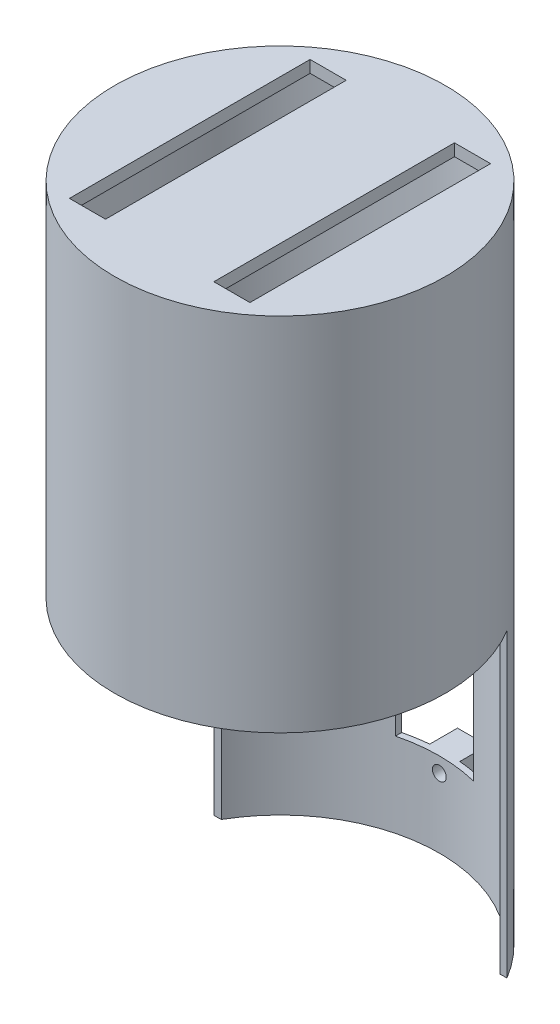
from build123d import *

# Parameters (mm, degrees)
EXTRUDE_1_DEPTH           = 60
EXTRUDE_1_DEPTH_BACK      = 50
SKETCH_1_R                = 27.5
SKETCH_10_W               = 6
SKETCH_10_H               = 40
CUT_EXTRUDE_8_DEPTH       = 8.1
CUT_EXTRUDE_9_DEPTH       = 10
CUT_EXTRUDE_9_DEPTH_BACK  = 10
SKETCH_10_2_W             = 6
SKETCH_10_2_H             = 40
CUT_EXTRUDE_10_DEPTH      = 54
CUT_EXTRUDE_11_DEPTH      = 58
CUT_EXTRUDE_11_DEPTH_BACK = 54
SKETCH_12_R               = 26.5
SKETCH_13_W               = 13
SKETCH_13_H               = 23.5
CUT_EXTRUDE_12_DEPTH      = 54
EXTRUDE_2_DEPTH           = 1
EXTRUDE_2_DEPTH_BACK      = 4
SKETCH_14_W               = 5
SKETCH_14_H               = 5
CUT_EXTRUDE_13_DEPTH      = 4
CUT_EXTRUDE_13_DEPTH_BACK = 5
SKETCH_15_R               = 1.15


with BuildPart() as part:
    # 草圖1 → 填料-伸長1 (new, two sides: drawn at the far end of the back side and taken through both)
    with BuildSketch(Plane(origin=(0, 0, 0), x_dir=(1, 0, 0), z_dir=(0, 1, 0)).offset(-EXTRUDE_1_DEPTH_BACK)):
        Circle(SKETCH_1_R)
    extrude(amount=EXTRUDE_1_DEPTH + EXTRUDE_1_DEPTH_BACK)

    # 草圖10 → 除料-伸長8 (cut)
    with BuildSketch(Plane(origin=(0, 60, 0), x_dir=(1, 0, 0), z_dir=(0, 1, 0))):
        with Locations((-12, 0)):
            Rectangle(SKETCH_10_W, SKETCH_10_H)
        with Locations((12, 0)):
            Rectangle(SKETCH_10_W, SKETCH_10_H)
    extrude(amount=-CUT_EXTRUDE_8_DEPTH, mode=Mode.SUBTRACT)

    # 草圖10<2> → 除料-伸長9 (cut, two sides: drawn at the far end of the back side and taken through both)
    with BuildSketch(Plane(origin=(0, 60, 0), x_dir=(1, 0, 0), z_dir=(0, 1, 0)).offset(-CUT_EXTRUDE_9_DEPTH_BACK)):
        with Locations((-12, 0)):
            Rectangle(SKETCH_10_2_W, SKETCH_10_2_H)
        with Locations((12, 0)):
            Rectangle(SKETCH_10_2_W, SKETCH_10_2_H)
    extrude(amount=CUT_EXTRUDE_9_DEPTH + CUT_EXTRUDE_9_DEPTH_BACK, mode=Mode.SUBTRACT)

    # 草圖11 → 除料-伸長10 (cut)
    with BuildSketch(Plane(origin=(0, 0, 0), x_dir=(1, 0, 0), z_dir=(0, 1, 0))):
        with BuildLine():
            Line((23.587956714, 14.137124816), (-24.13203639, 13.186918505))
            ThreePointArc((-24.13203639, 13.186918505), (0.547474823, -27.494549848), (23.587956714, 14.137124816))
        make_face()
    extrude(amount=-CUT_EXTRUDE_10_DEPTH, mode=Mode.SUBTRACT)

    # 草圖12 → 除料-伸長11 (cut, two sides: drawn at the far end of the back side and taken through both)
    with BuildSketch(Plane(origin=(0, 0, 0), x_dir=(1, 0, 0), z_dir=(0, 1, 0)).offset(-CUT_EXTRUDE_11_DEPTH_BACK)):
        Circle(SKETCH_12_R)
    extrude(amount=CUT_EXTRUDE_11_DEPTH + CUT_EXTRUDE_11_DEPTH_BACK, mode=Mode.SUBTRACT)

    # 草圖13 → 除料-伸長12 (cut)
    with BuildSketch(Plane.XY):
        with Locations((0, -24.25)):
            Rectangle(SKETCH_13_W, SKETCH_13_H)
    extrude(amount=-CUT_EXTRUDE_12_DEPTH, mode=Mode.SUBTRACT)

    # 草圖14 → 填料-伸長2 (add, two sides: drawn at the far end of the back side and taken through both)
    with BuildSketch(Plane.XY.offset(-28).offset(-EXTRUDE_2_DEPTH_BACK)):
        with Locations((0, -38.5)):
            Rectangle(SKETCH_14_W, SKETCH_14_H)
        with Locations((0, -10)):
            Rectangle(SKETCH_14_W, SKETCH_14_H)
    extrude(amount=EXTRUDE_2_DEPTH + EXTRUDE_2_DEPTH_BACK)

    # 草圖15 → 除料-伸長13 (cut, two sides: drawn at the far end of the back side and taken through both)
    with BuildSketch(Plane.XY.offset(-28).offset(-CUT_EXTRUDE_13_DEPTH_BACK)):
        with Locations((0, -10)):
            Circle(SKETCH_15_R)
        with Locations((0, -38.5)):
            Circle(SKETCH_15_R)
    extrude(amount=CUT_EXTRUDE_13_DEPTH + CUT_EXTRUDE_13_DEPTH_BACK, mode=Mode.SUBTRACT)


solid = part.part
